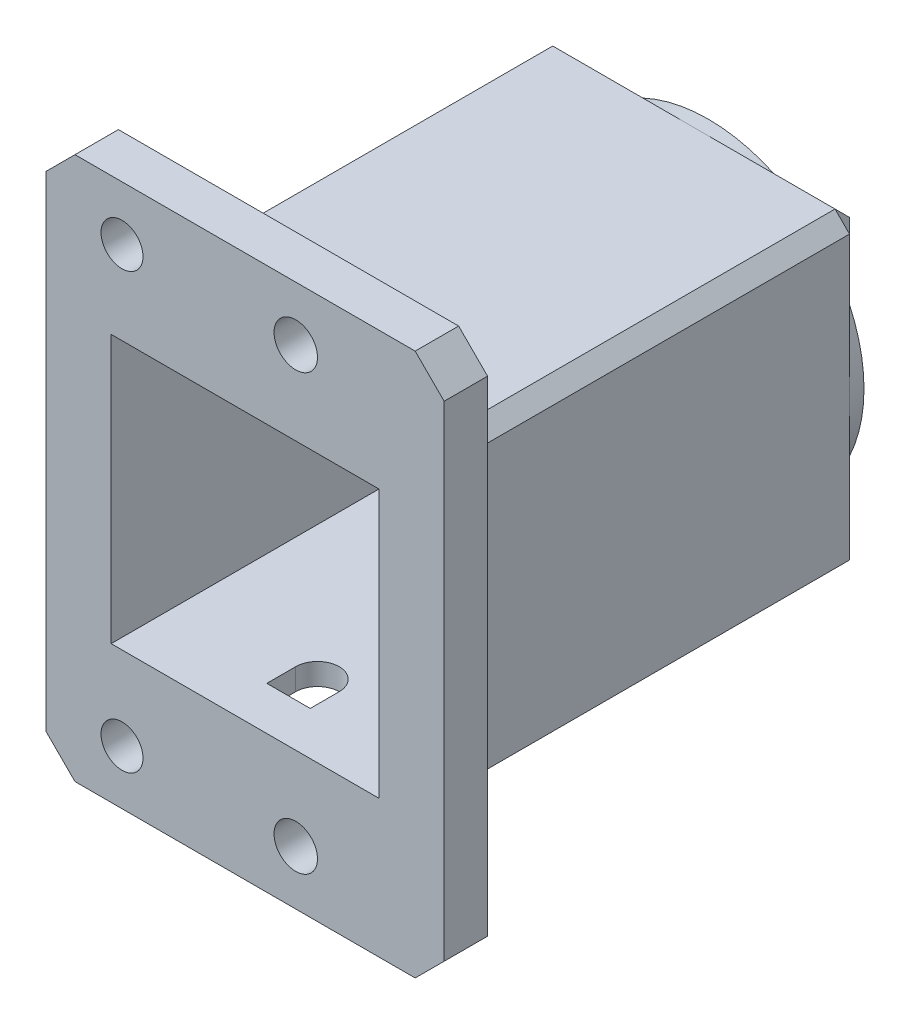
from build123d import *

# Parameters (mm, degrees)
SKETCH1_W           = 21.5
SKETCH1_H           = 21.5
SKETCH1_R           = 8
BOSS_EXTRUDE1_DEPTH = 2
SKETCH2_W           = 21.5
SKETCH2_H           = 21.5
SKETCH2_W_2         = 18.5
SKETCH2_H_2         = 18.5
BOSS_EXTRUDE2_DEPTH = 30
SKETCH3_W           = 27.5
SKETCH3_H           = 37.5
SKETCH3_R           = 1.5
SKETCH3_W_2         = 21.5
SKETCH3_H_2         = 21.5
BOSS_EXTRUDE3_DEPTH = 3
CUT_EXTRUDE1_DEPTH  = 3
CHAMFER1_SIZE       = 1
CHAMFER2_SIZE       = 2
SKETCH5_R           = 1.5
SKETCH5_R_2         = 1.45
BOSS_EXTRUDE4_DEPTH = 3
SKETCH6_R           = 10.75
SKETCH6_R_2         = 8
BOSS_EXTRUDE5_DEPTH = 1.5


with BuildPart() as part:
    # Sketch1 → Boss-Extrude1 (new body)
    with BuildSketch(Plane.XY):
        Rectangle(SKETCH1_W, SKETCH1_H)
        Circle(SKETCH1_R, mode=Mode.SUBTRACT)
    extrude(amount=BOSS_EXTRUDE1_DEPTH)

    # Sketch2 → Boss-Extrude2 (add)
    with BuildSketch(Plane.XY.offset(2)):
        Rectangle(SKETCH2_W, SKETCH2_H)
        Rectangle(SKETCH2_W_2, SKETCH2_H_2, mode=Mode.SUBTRACT)
    extrude(amount=BOSS_EXTRUDE2_DEPTH)

    # Sketch3 → Boss-Extrude3 (add)
    with BuildSketch(Plane.XY.offset(32)):
        Rectangle(SKETCH3_W, SKETCH3_H)
        with Locations((3.5, -15)):
            Circle(SKETCH3_R, mode=Mode.SUBTRACT)
        with Locations((3.5, 15)):
            Circle(SKETCH3_R, mode=Mode.SUBTRACT)
        with Locations((-8.5, 15)):
            Circle(SKETCH3_R, mode=Mode.SUBTRACT)
        with Locations((-8.5, -15)):
            Circle(SKETCH3_R, mode=Mode.SUBTRACT)
        Rectangle(SKETCH3_W_2, SKETCH3_H_2, mode=Mode.SUBTRACT)
    extrude(amount=-BOSS_EXTRUDE3_DEPTH)

    # Sketch4 → Cut-Extrude1 (cut)
    with BuildSketch(Plane.XZ.offset(10.75)):
        with BuildLine():
            Line((-1.5, 29), (-1.5, 27))
            ThreePointArc((-1.5, 27), (0, 25.5), (1.5, 27))
            Line((1.5, 27), (1.5, 29))
            Line((1.5, 29), (-1.5, 29))
        make_face()
    extrude(amount=-CUT_EXTRUDE1_DEPTH, mode=Mode.SUBTRACT)

    # Chamfer1
    chamfer1_edges = [part.edges().sort_by_distance(p)[0] for p in [
        (-10.75, 10.75, 14.5),
        (10.75, 10.75, 14.5),
        (10.75, -10.75, 14.5),
        (-10.75, -10.75, 14.5),
        (0, 10.75, 0),
        (10.75, 0, 0),
        (0, -10.75, 0),
        (-10.75, 0, 0),
    ]]
    chamfer(chamfer1_edges, length=CHAMFER1_SIZE)

    # Chamfer2
    chamfer2_edges = [part.edges().sort_by_distance(p)[0] for p in [
        (13.75, 18.75, 30.5),
        (13.75, -18.75, 30.5),
        (-13.75, -18.75, 30.5),
        (-13.75, 18.75, 30.5),
    ]]
    chamfer(chamfer2_edges, length=CHAMFER2_SIZE)

    # Sketch5 → Boss-Extrude4 (add)
    with BuildSketch(Plane(origin=(0, 0, 29), x_dir=(-1, 0, 0), z_dir=(0, 0, -1))):
        with Locations((8.5, -15)):
            Circle(SKETCH5_R)
        with Locations((8.5, -15)):
            Circle(SKETCH5_R_2, mode=Mode.SUBTRACT)
        with Locations((8.5, 15)):
            Circle(SKETCH5_R)
        with Locations((8.5, 15)):
            Circle(SKETCH5_R_2, mode=Mode.SUBTRACT)
    extrude(amount=-BOSS_EXTRUDE4_DEPTH)

    # Sketch6 → Boss-Extrude5 (add)
    with BuildSketch(Plane(origin=(0, 0, 0), x_dir=(-1, 0, 0), z_dir=(0, 0, -1))):
        Circle(SKETCH6_R)
        Circle(SKETCH6_R_2, mode=Mode.SUBTRACT)
    extrude(amount=-BOSS_EXTRUDE5_DEPTH)


solid = part.part
